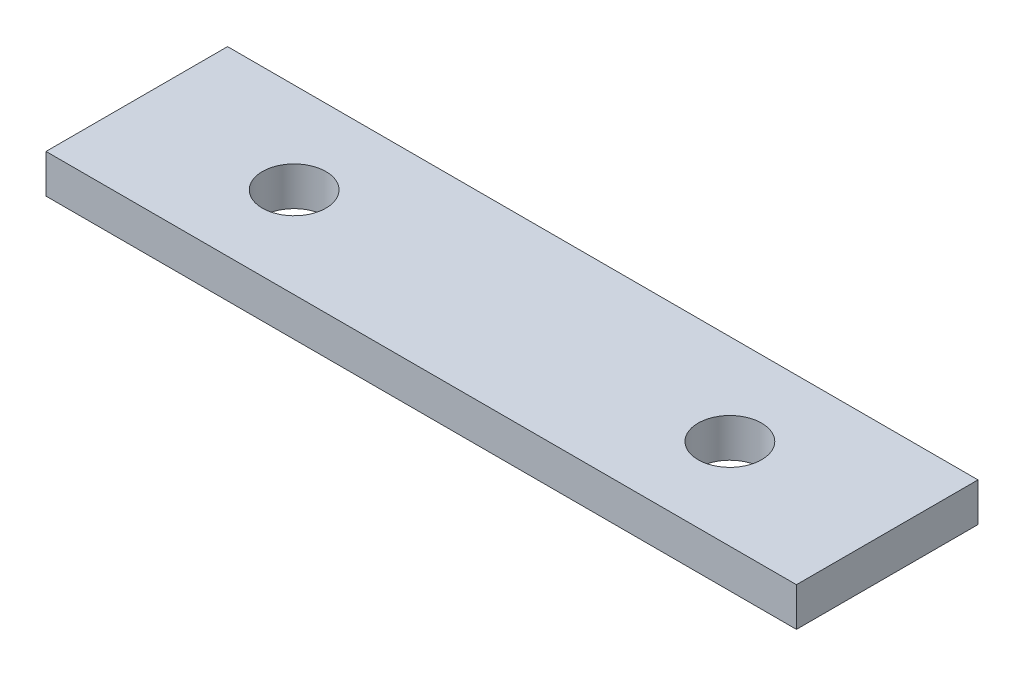
from build123d import *

# Parameters (mm, degrees)
SKETCH1_W           = 62
SKETCH1_H           = 15
BOSS_EXTRUDE1_DEPTH = 3.2
CUT_EXTRUDE1_REACH  = 5.2
SKETCH2_R           = 2.625


with BuildPart() as part:
    # Sketch1 → Boss-Extrude1 (new body)
    with BuildSketch(Plane(origin=(0, 0, 0), x_dir=(1, 0, 0), z_dir=(0, 1, 0))):
        Rectangle(SKETCH1_W, SKETCH1_H)
    extrude(amount=BOSS_EXTRUDE1_DEPTH)

    # Sketch2 → Cut-Extrude1 (cut, up to next)
    with BuildSketch(Plane(origin=(0, 3.2, 0), x_dir=(1, 0, 0), z_dir=(0, 1, 0)), mode=Mode.PRIVATE) as cut_extrude1_sk1:
        with Locations((-18, 0)):
            Circle(SKETCH2_R)
    cut_extrude1_tool1 = extrude(cut_extrude1_sk1.sketch, amount=-CUT_EXTRUDE1_REACH, mode=Mode.PRIVATE) & part.part
    add(cut_extrude1_tool1.solids().sort_by_distance((-18, 3.2, 0))[0], mode=Mode.SUBTRACT)
    # Sketch2 → Cut-Extrude1 (cut, up to next)
    with BuildSketch(Plane(origin=(0, 3.2, 0), x_dir=(1, 0, 0), z_dir=(0, 1, 0)), mode=Mode.PRIVATE) as cut_extrude1_sk2:
        with Locations((18, 0)):
            Circle(SKETCH2_R)
    cut_extrude1_tool2 = extrude(cut_extrude1_sk2.sketch, amount=-CUT_EXTRUDE1_REACH, mode=Mode.PRIVATE) & part.part
    add(cut_extrude1_tool2.solids().sort_by_distance((18, 3.2, 0))[0], mode=Mode.SUBTRACT)


solid = part.part
